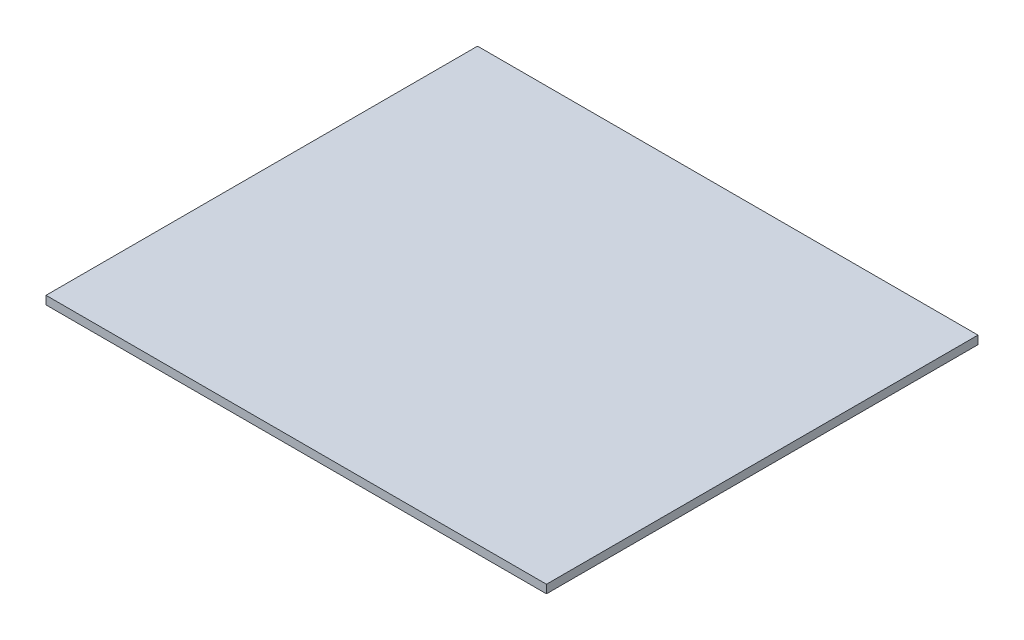
from build123d import *

# Parameters (mm, degrees)
SKETCH1_W           = 600
SKETCH1_H           = 503.37
SKETCH1_H_2         = 7
BOSS_EXTRUDE1_DEPTH = 10


with BuildPart() as part:
    # Sketch1 → Boss-Extrude1 (new body)
    with BuildSketch(Plane(origin=(0, 0, 0), x_dir=(1, 0, 0), z_dir=(0, 1, 0))):
        with Locations((200, 258.685)):
            Rectangle(SKETCH1_W, SKETCH1_H)
        with Locations((200, 513.87)):
            Rectangle(SKETCH1_W, SKETCH1_H_2)
        with Locations((200, 3.5)):
            Rectangle(SKETCH1_W, SKETCH1_H_2)
    extrude(amount=BOSS_EXTRUDE1_DEPTH)


solid = part.part
